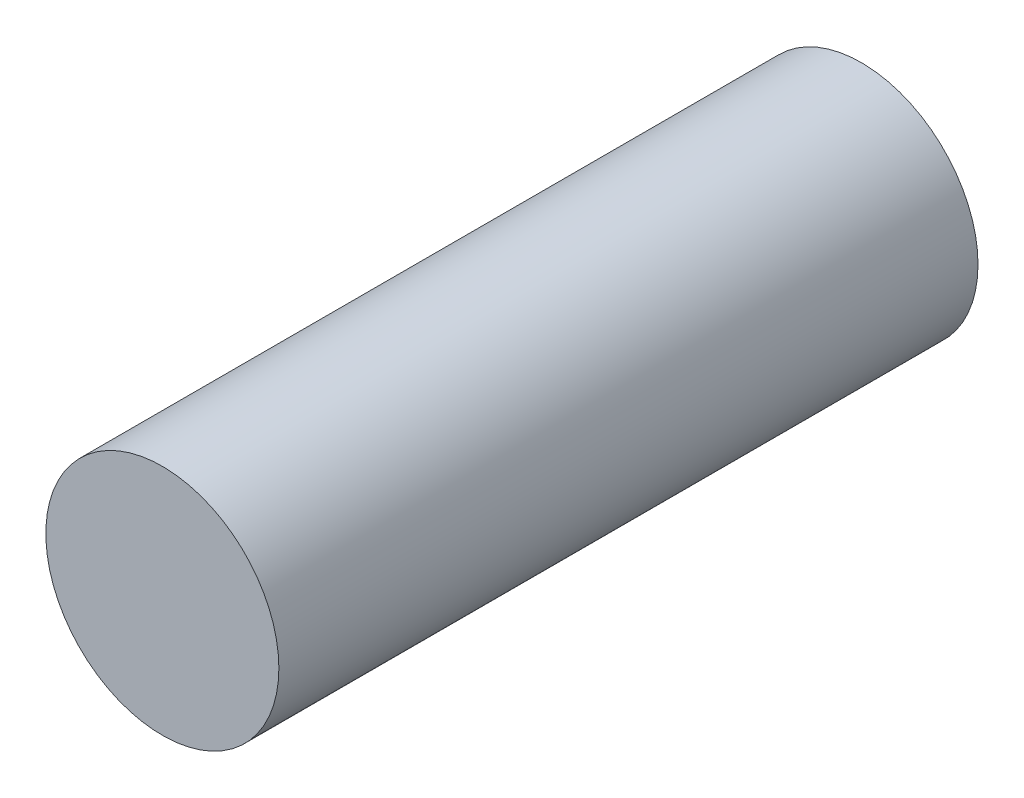
from build123d import *

# Parameters (mm, degrees)
CROQUIS1_R              = 0.5
SALIENTE_EXTRUIR1_DEPTH = 3


with BuildPart() as part:
    # Croquis1 → Saliente-Extruir1 (new body)
    with BuildSketch(Plane.XY):
        Circle(CROQUIS1_R)
    extrude(amount=SALIENTE_EXTRUIR1_DEPTH)


solid = part.part
